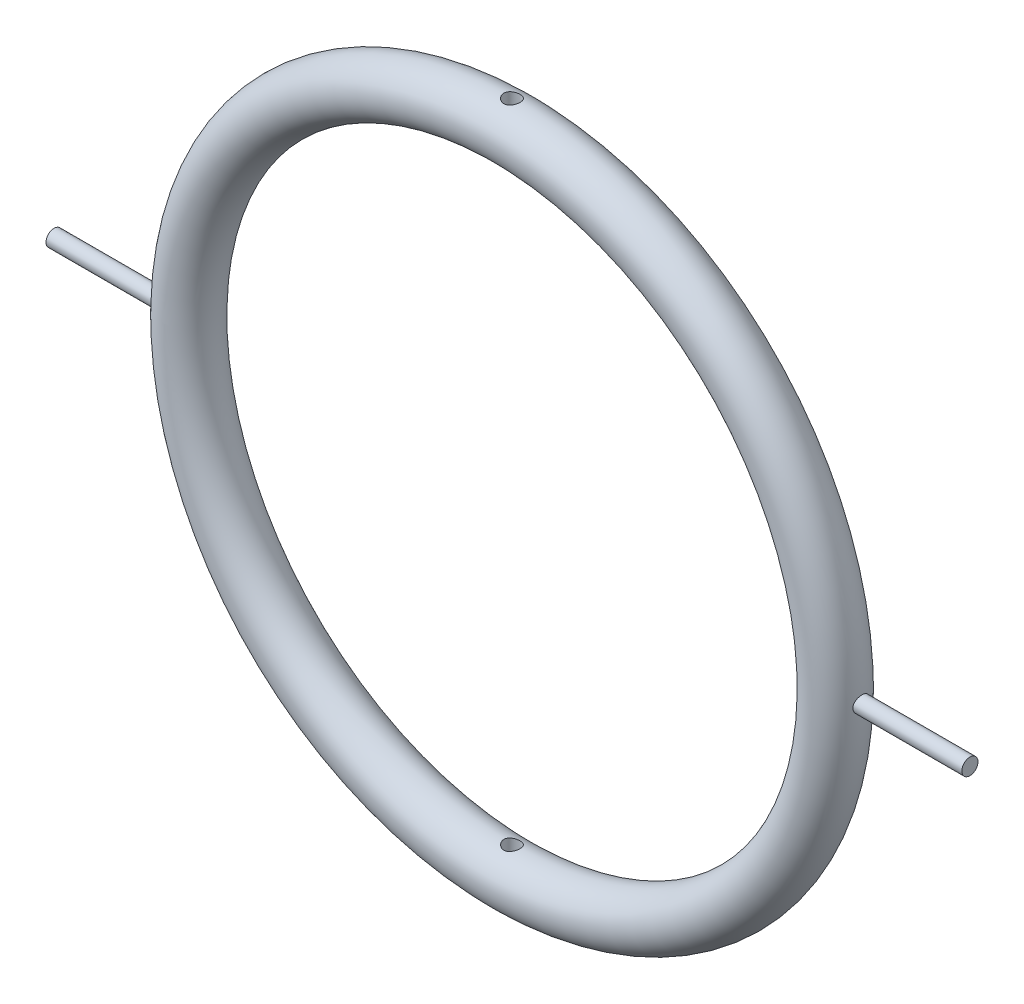
from build123d import *
from build123d.topology import SkipClean

# Parameters (mm, degrees)
SKETCH1_R                      = 2.5
BOSS_EXTRUDE1_REACH            = 83.777
BOSS_EXTRUDE1_END_MAJOR_RADIUS = 30
BOSS_EXTRUDE1_END_MINOR_RADIUS = 2.5
SKETCH3_R                      = 0.75
SKETCH4_R                      = 0.75
CUT_EXTRUDE1_DEPTH             = 54.560713359
CUT_EXTRUDE1_DEPTH_BACK        = 54.560713359


with BuildPart() as part:
    # Sketch1 → Revolve1 (revolve)
    with BuildSketch(Plane(origin=(0, 0, 0), x_dir=(1, 0, 0), z_dir=(0, 1, 0))):
        with Locations((-30, 0)):
            Circle(SKETCH1_R)
    revolve(axis=Axis((0, 0, -16.246129114), (0, 0, 1)))

    # Boss-Extrude1: up to this torus (the profile starts outside it)
    boss_extrude1_end = Plane(origin=(0, 0, 0), z_dir=(0, 0, -1)) * Torus(BOSS_EXTRUDE1_END_MAJOR_RADIUS, BOSS_EXTRUDE1_END_MINOR_RADIUS, mode=Mode.PRIVATE)
    # Sketch3 → Boss-Extrude1 (add, up to the surface)
    with BuildSketch(Plane(origin=(42.5, 0, 0), x_dir=(0, 0, -1), z_dir=(1, 0, 0)), mode=Mode.PRIVATE) as boss_extrude1_sk1:
        Circle(SKETCH3_R)
    boss_extrude1_tool1 = extrude(boss_extrude1_sk1.sketch, amount=-BOSS_EXTRUDE1_REACH, mode=Mode.PRIVATE) - boss_extrude1_end
    boss_extrude1 = boss_extrude1_tool1.solids().sort_by_distance((42.5, 0, 0))[0]
    add(boss_extrude1)

    # Mirror1: Boss-Extrude1 across plane
    add(boss_extrude1.mirror(Plane(origin=(0, 0, 0), x_dir=(0, 0, 1), z_dir=(1, 0, 0))))

    # Sketch4 → Cut-Extrude1 (cut, two sides)
    with SkipClean():  # the faces are left unmerged after this step: merging them gives an invalid solid
        with BuildSketch(Plane(origin=(0, 0, 0), x_dir=(1, 0, 0), z_dir=(0, 1, 0))) as cut_extrude1_sk:
            with Locations(Location((0, 0, 0), (0, 0, 138.121355577))):
                Circle(SKETCH4_R)
        extrude(amount=CUT_EXTRUDE1_DEPTH, mode=Mode.SUBTRACT)
        extrude(cut_extrude1_sk.sketch, amount=-CUT_EXTRUDE1_DEPTH_BACK, mode=Mode.SUBTRACT)


solid = part.part
